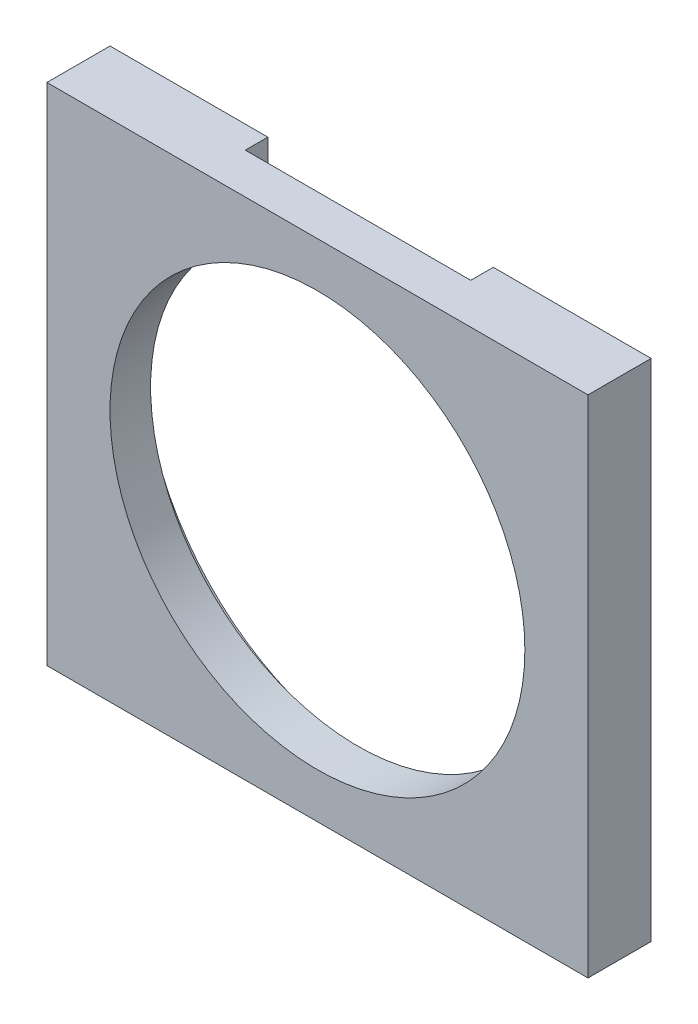
from build123d import *

# Parameters (mm, degrees)
BOSS_EXTRUDE1_DEPTH = 6.35
SKETCH2_W           = 152.4
SKETCH2_H           = 142.24
SKETCH2_R           = 58.42
BOSS_EXTRUDE2_DEPTH = 11.43


with BuildPart() as part:
    # Sketch1 → Boss-Extrude1 (new body)
    with BuildSketch(Plane.XY):
        with BuildLine():
            Line((-31.75, 71.12), (-76.2, 71.12))
            Line((-76.2, 71.12), (-76.2, -71.12))
            Line((-76.2, -71.12), (76.2, -71.12))
            Line((76.2, -71.12), (76.2, 71.12))
            Line((76.2, 71.12), (31.75, 71.12))
            Line((31.75, 71.12), (31.75, 58.630138368))
            ThreePointArc((31.75, 58.630138368), (0, -66.675), (-31.75, 58.630138368))
            Line((-31.75, 58.630138368), (-31.75, 71.12))
        make_face()
    extrude(amount=BOSS_EXTRUDE1_DEPTH)

    # Sketch2 → Boss-Extrude2 (add)
    with BuildSketch(Plane.XY.offset(6.35)):
        Rectangle(SKETCH2_W, SKETCH2_H)
        Circle(SKETCH2_R, mode=Mode.SUBTRACT)
    extrude(amount=BOSS_EXTRUDE2_DEPTH)


solid = part.part
